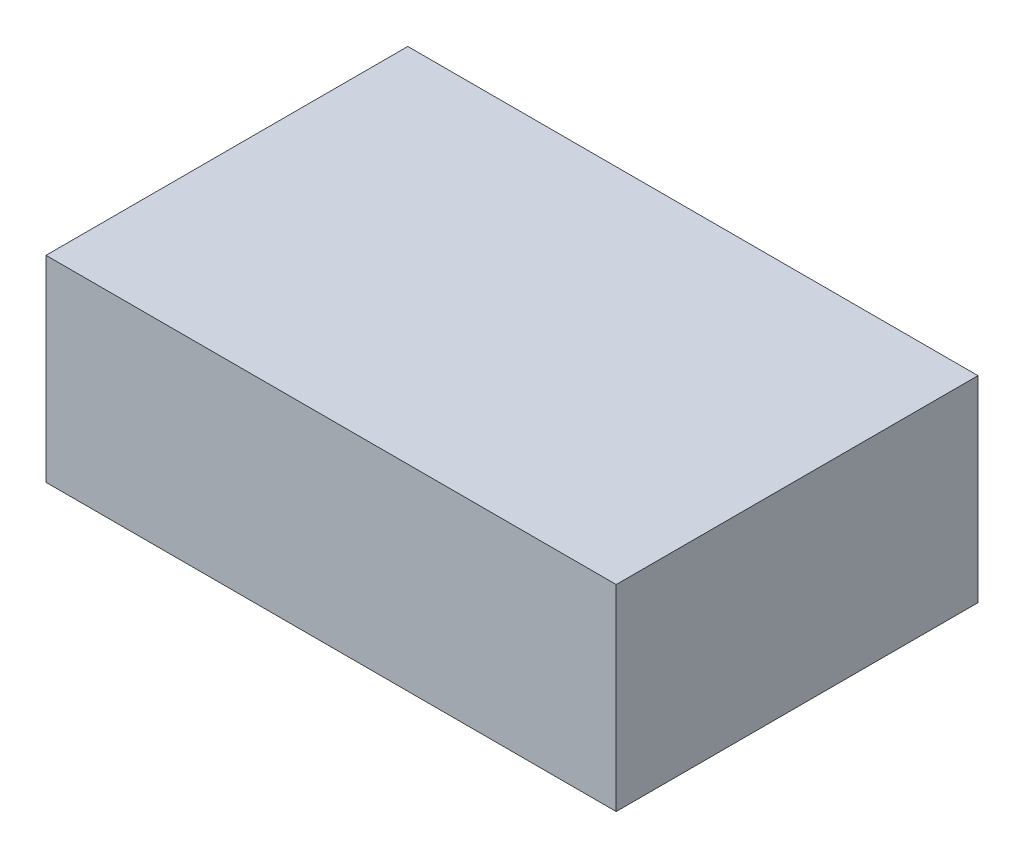
from build123d import *

# Parameters (mm, degrees)
SKIZZE1_W                       = 145
SKIZZE1_H                       = 92
AUFSATZ_LINEAR_AUSTRAGEN1_DEPTH = 25


with BuildPart() as part:
    # Skizze1 → Aufsatz-Linear austragen1 (new body, symmetric)
    with BuildSketch(Plane(origin=(0, 0, 0), x_dir=(1, 0, 0), z_dir=(0, 1, 0))):
        Rectangle(SKIZZE1_W, SKIZZE1_H)
    extrude(amount=AUFSATZ_LINEAR_AUSTRAGEN1_DEPTH, both=True)


solid = part.part
